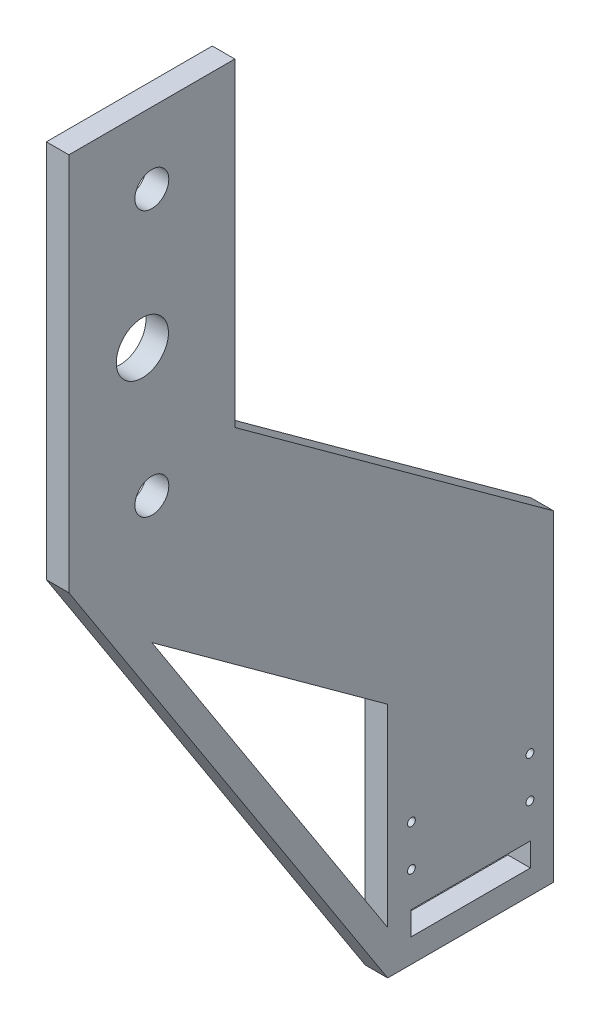
from build123d import *

# Parameters (mm, degrees)
SKETCH1_R           = 7.15
SKETCH1_R_2         = 11
SKETCH1_W           = 50.4
SKETCH1_H           = 9.9
BOSS_EXTRUDE1_DEPTH = 9.5
M4_TAPPED_HOLE1_D   = 3.3


with BuildPart() as part:
    # Sketch1 → Boss-Extrude1 (new body)
    with BuildSketch(Plane(origin=(0, 0, 0), x_dir=(0, 0, -1), z_dir=(1, 0, 0))):
        Polygon((0, 0), (70, 0), (70, 135.667122158), (-64.5, 233.385504136), (-64.5, 368), (-134.5, 368), (-134.5, 208), align=None)
        with Locations((-99.5, 338)):
            Circle(SKETCH1_R, mode=Mode.SUBTRACT)
        with Locations((-99.5, 226)):
            Circle(SKETCH1_R, mode=Mode.SUBTRACT)
        with Locations((-103.5, 282)):
            Circle(SKETCH1_R_2, mode=Mode.SUBTRACT)
        Polygon((0, 18.416200794), (0, 100), (-99.5, 172.289806742), align=None, mode=Mode.SUBTRACT)
        with Locations((35, 15.05)):
            Rectangle(SKETCH1_W, SKETCH1_H, mode=Mode.SUBTRACT)
    extrude(amount=BOSS_EXTRUDE1_DEPTH)

    # M4 Tapped Hole1 (through all)
    with Locations(Plane(origin=(9.5, 0, 0), x_dir=(0, 0, -1), z_dir=(1, 0, 0))):
        with Locations((10, 34.7), (10, 52), (60, 34.7), (60, 52)):
            Hole(M4_TAPPED_HOLE1_D / 2)


solid = part.part
